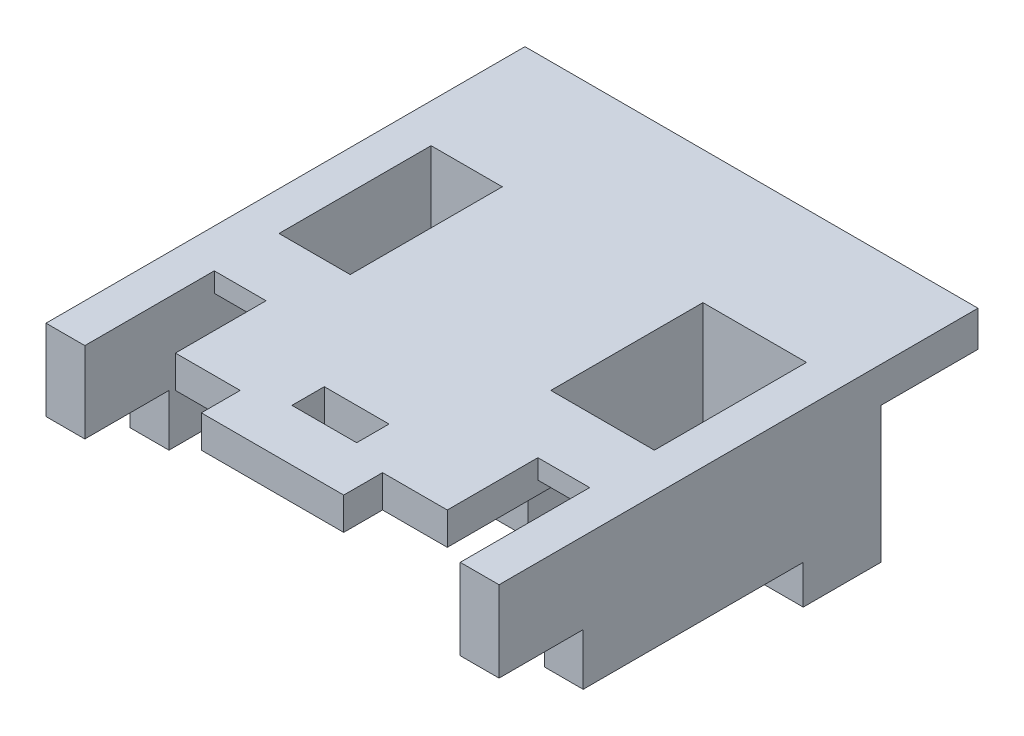
from build123d import *

# Parameters (mm, degrees)
BOSS_EXTRUDE1_DEPTH  = 20.5
SKETCH2_W            = 6
SKETCH2_H            = 13
CUT_EXTRUDE1_DEPTH   = 8
SKETCH3_W            = 23
SKETCH3_H            = 23
BOSS_EXTRUDE2_DEPTH  = 6
BOSS_EXTRUDE4_DEPTH  = 18
SKETCH5_W            = 2.6
SKETCH5_H            = 5.5
SKETCH5_H_2          = 4
SKETCH5_W_2          = 4
SKETCH5_H_3          = 15
SKETCH5_W_3          = 2
CUT_EXTRUDE2_DEPTH   = 14.5
SKETCH9_W            = 70
SKETCH9_H            = 5.5
BOSS_EXTRUDE6_DEPTH  = 15
BOSS_EXTRUDE7_DEPTH  = 7.5
CUT_EXTRUDE3_DEPTH   = 5.5
BOSS_EXTRUDE8_DEPTH  = 6
BOSS_EXTRUDE10_START = -6
BOSS_EXTRUDE10_DEPTH = 58
BOSS_EXTRUDE11_START = -14
SKETCH15_W           = 10
SKETCH15_H           = 5
BOSS_EXTRUDE11_DEPTH = 42
SKETCH16_W           = 42
SKETCH16_H           = 5
BOSS_EXTRUDE12_DEPTH = 20
CUT_EXTRUDE4_REACH   = 28.5
SKETCH17_W           = 10
SKETCH17_H           = 6
SKETCH17_H_2         = 5


with BuildPart() as part:
    # Sketch1 → Boss-Extrude1 (new body)
    with BuildSketch(Plane(origin=(0, 0, 0), x_dir=(1, 0, 0), z_dir=(0, 1, 0))):
        Polygon((29, -29.5), (35, -29.5), (35, 29.5), (-35, 29.5), (-35, -29.5), (-29, -29.5), (-29, 24), (29, 24), align=None)
    extrude(amount=BOSS_EXTRUDE1_DEPTH)

    # Sketch2 → Cut-Extrude1 (cut)
    with BuildSketch(Plane.XZ):
        with Locations((32, 23)):
            Rectangle(SKETCH2_W, SKETCH2_H)
        with Locations((-32, 23)):
            Rectangle(SKETCH2_W, SKETCH2_H)
    extrude(amount=-CUT_EXTRUDE1_DEPTH, mode=Mode.SUBTRACT)



with BuildPart() as body_2:
    # Sketch3 → Boss-Extrude2 (new body)
    with BuildSketch(Plane(origin=(0, 20.5, 0), x_dir=(1, 0, 0), z_dir=(0, 1, 0))):
        with Locations((-2.5, 12.5)):
            Rectangle(SKETCH3_W, SKETCH3_H)
    extrude(amount=-BOSS_EXTRUDE2_DEPTH)


with BuildPart() as part_1:
    add(part.part)

    add(body_2.part)  # Boss-Extrude4 merges body 2
    # Sketch4 → Boss-Extrude4 (add)
    with BuildSketch(Plane(origin=(0, 20.5, 0), x_dir=(1, 0, 0), z_dir=(0, 1, 0))):
        Polygon((-14, 24), (-18, 24), (-18, -3), (13, -3), (13, 24), (9, 24), (9, 1), (-14, 1), align=None)
    extrude(amount=-BOSS_EXTRUDE4_DEPTH)

    # Sketch5 → Cut-Extrude2 (cut)
    with BuildSketch(Plane.XZ):
        with Locations((-8.25, -26.75)):
            Rectangle(SKETCH5_W, SKETCH5_H)
        with Locations((-8.25, 1)):
            Rectangle(SKETCH5_W, SKETCH5_H_2)
        with Locations((-16, -8.5)):
            Rectangle(SKETCH5_W_2, SKETCH5_H_3)
        with Locations((3.55, 1)):
            Rectangle(SKETCH5_W_3, SKETCH5_H_2)
    extrude(amount=-CUT_EXTRUDE2_DEPTH, mode=Mode.SUBTRACT)

    # Sketch9 → Boss-Extrude6 (add)
    with BuildSketch(Plane(origin=(0, 0, -29.5), x_dir=(-1, 0, 0), z_dir=(0, 0, -1))):
        with Locations((0, 17.75)):
            Rectangle(SKETCH9_W, SKETCH9_H)
    extrude(amount=BOSS_EXTRUDE6_DEPTH)

    # Sketch10 → Boss-Extrude7 (add)
    with BuildSketch(Plane.XZ.offset(-15)):
        Polygon((11.5, -29.5), (-11.5, -29.5), (-14.5, -37), (14.5, -37), align=None)
    extrude(amount=BOSS_EXTRUDE7_DEPTH)

    # Sketch11 → Cut-Extrude3 (cut)
    with BuildSketch(Plane(origin=(0, 0, -29.5), x_dir=(-1, 0, 0), z_dir=(0, 0, -1))):
        with BuildLine():
            Line((-7.5, 2.5), (7.5, 2.5))
            ThreePointArc((7.5, 2.5), (10, 0), (7.5, -2.5))
            Line((7.5, -2.5), (-7.5, -2.5))
            ThreePointArc((-7.5, -2.5), (-10, 0), (-7.5, 2.5))
        make_face()
    extrude(amount=-CUT_EXTRUDE3_DEPTH, mode=Mode.SUBTRACT)

    # Sketch12 → Boss-Extrude8 (add)
    with BuildSketch(Plane.XZ):
        Polygon((35, -17.5), (29, -17.5), (29, -24), (23, -24), (23, -29.5), (35, -29.5), align=None)
        Polygon((-23, -24), (-23, -29.5), (-35, -29.5), (-35, -17.5), (-29, -17.5), (-29, -24), align=None)
    extrude(amount=BOSS_EXTRUDE8_DEPTH)

    # Sketch14 → Boss-Extrude10 (add)
    with BuildSketch(Plane(origin=(35, 0, 0), x_dir=(0, 0, -1), z_dir=(1, 0, 0)).offset(BOSS_EXTRUDE10_START)):
        Polygon((-9.5, 20.5), (0.5, 20.5), (0.5, 18.5), (-2.5, 15.5), (-6.5, 15.5), (-9.5, 17.5), align=None)
    extrude(amount=-BOSS_EXTRUDE10_DEPTH)

    # Sketch15 → Boss-Extrude11 (add)
    with BuildSketch(Plane(origin=(35, 0, 0), x_dir=(0, 0, -1), z_dir=(1, 0, 0)).offset(BOSS_EXTRUDE11_START)):
        with Locations((-4.5, 18)):
            Rectangle(SKETCH15_W, SKETCH15_H)
    extrude(amount=-BOSS_EXTRUDE11_DEPTH)

    # Sketch16 → Boss-Extrude12 (add)
    with BuildSketch(Plane.XY.offset(9.5)):
        with Locations((0, 18)):
            Rectangle(SKETCH16_W, SKETCH16_H)
    extrude(amount=BOSS_EXTRUDE12_DEPTH)

    # Sketch17 → Cut-Extrude4 (cut, up to next)
    with BuildSketch(Plane(origin=(0, 20.5, 0), x_dir=(1, 0, 0), z_dir=(0, 1, 0)), mode=Mode.PRIVATE) as cut_extrude4_sk1:
        with Locations((-16, -26.5)):
            Rectangle(SKETCH17_W, SKETCH17_H)
    cut_extrude4_tool1 = extrude(cut_extrude4_sk1.sketch, amount=-CUT_EXTRUDE4_REACH, mode=Mode.PRIVATE) & part_1.part
    add(cut_extrude4_tool1.solids().sort_by_distance((-16, 20.5, 26.5))[0], mode=Mode.SUBTRACT)
    # Sketch17 → Cut-Extrude4 (cut, up to next)
    with BuildSketch(Plane(origin=(0, 20.5, 0), x_dir=(1, 0, 0), z_dir=(0, 1, 0)), mode=Mode.PRIVATE) as cut_extrude4_sk2:
        with Locations((16, -26.5)):
            Rectangle(SKETCH17_W, SKETCH17_H)
    cut_extrude4_tool2 = extrude(cut_extrude4_sk2.sketch, amount=-CUT_EXTRUDE4_REACH, mode=Mode.PRIVATE) & part_1.part
    add(cut_extrude4_tool2.solids().sort_by_distance((16, 20.5, 26.5))[0], mode=Mode.SUBTRACT)
    # Sketch17 → Cut-Extrude4 (cut, up to next)
    with BuildSketch(Plane(origin=(0, 20.5, 0), x_dir=(1, 0, 0), z_dir=(0, 1, 0)), mode=Mode.PRIVATE) as cut_extrude4_sk3:
        with Locations((0, -19)):
            Rectangle(SKETCH17_W, SKETCH17_H_2)
    cut_extrude4_tool3 = extrude(cut_extrude4_sk3.sketch, amount=-CUT_EXTRUDE4_REACH, mode=Mode.PRIVATE) & part_1.part
    add(cut_extrude4_tool3.solids().sort_by_distance((0, 20.5, 19))[0], mode=Mode.SUBTRACT)


solid = part_1.part
